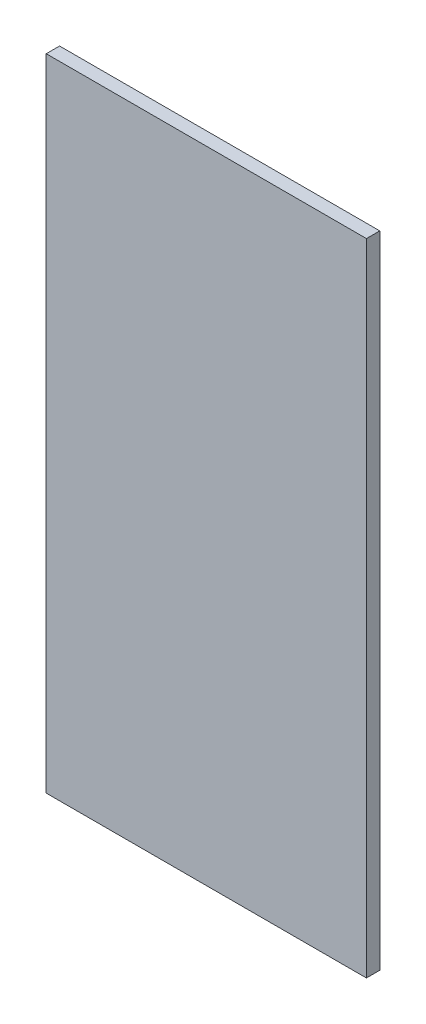
from build123d import *

# Parameters (mm, degrees)
SKETCH1_W           = 609.6
SKETCH1_H           = 1219.2
BOSS_EXTRUDE1_DEPTH = 25.4


with BuildPart() as part:
    # Sketch1 → Boss-Extrude1 (new body)
    with BuildSketch(Plane.XY):
        with Locations((304.8, -609.6)):
            Rectangle(SKETCH1_W, SKETCH1_H)
    extrude(amount=BOSS_EXTRUDE1_DEPTH)


solid = part.part
